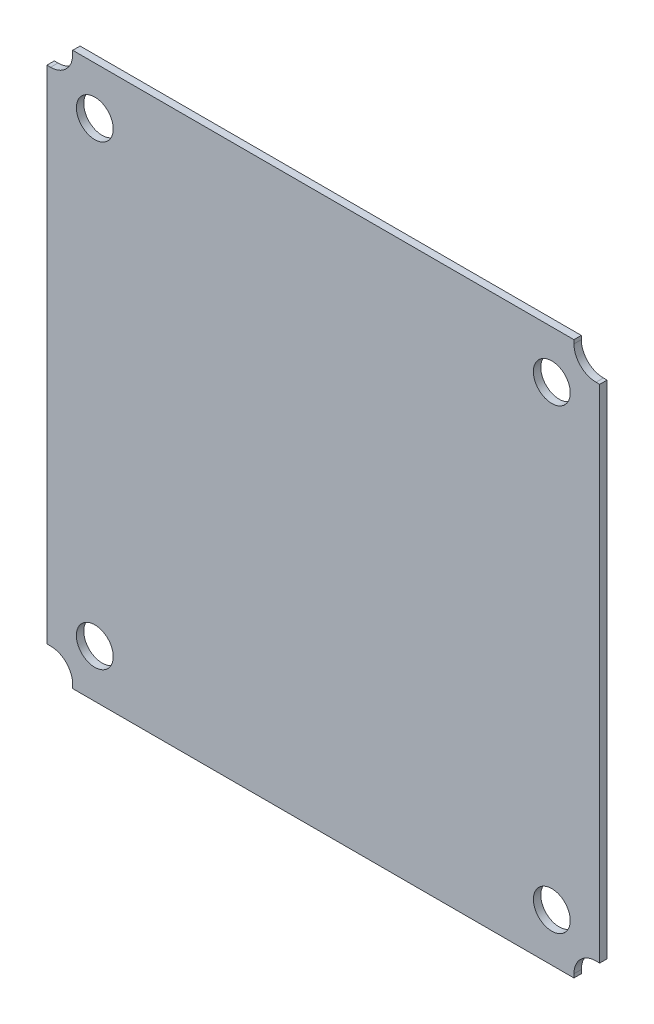
from build123d import *

# Parameters (mm, degrees)
SKETCH_1_W          = 68
SKETCH_1_H          = 68
SKETCH_1_R          = 2.5
SKETCH_1_H_2        = 11
SKETCH_1_W_2        = 11
EXTRUDE_2_DEPTH     = 1
FILLET_1_R          = 3
SKETCH_2_W          = 7.5
SKETCH_2_H          = 68
SKETCH_2_W_2        = 68
SKETCH_2_H_2        = 7.5
CUT_EXTRUDE_1_DEPTH = 2


with BuildPart() as part:
    # ｽｹｯﾁ1 → ﾎﾞｽ - 押し出し2 (new body)
    with BuildSketch(Plane.XY):
        Rectangle(SKETCH_1_W, SKETCH_1_H)
        with Locations((-31, -31)):
            Circle(SKETCH_1_R, mode=Mode.SUBTRACT)
        with Locations((31, -31)):
            Circle(SKETCH_1_R, mode=Mode.SUBTRACT)
        with Locations((-31, 31)):
            Circle(SKETCH_1_R, mode=Mode.SUBTRACT)
        with Locations((31, 31)):
            Circle(SKETCH_1_R, mode=Mode.SUBTRACT)
        with Locations((0, 39.5)):
            Rectangle(SKETCH_1_W, SKETCH_1_H_2)
        with Locations((-39.5, 0)):
            Rectangle(SKETCH_1_W_2, SKETCH_1_H)
        with Locations((39.5, 0)):
            Rectangle(SKETCH_1_W_2, SKETCH_1_H)
        with Locations((0, -39.5)):
            Rectangle(SKETCH_1_W, SKETCH_1_H_2)
    extrude(amount=EXTRUDE_2_DEPTH)

    # ﾌｨﾚｯﾄ1
    fillet_1_edges = [part.edges().sort_by_distance(p)[0] for p in [
        (-34, -34, 0.5),
        (-34, 34, 0.5),
        (34, 34, 0.5),
        (34, -34, 0.5),
    ]]
    fillet(fillet_1_edges, radius=FILLET_1_R)

    # ｽｹｯﾁ2 → ｶｯﾄ - 押し出し1 (cut, through all)
    with BuildSketch(Plane.XY.offset(1)):
        with Locations((-41.25, 0)):
            Rectangle(SKETCH_2_W, SKETCH_2_H)
        with Locations((0, 41.25)):
            Rectangle(SKETCH_2_W_2, SKETCH_2_H_2)
        with Locations((41.25, 0)):
            Rectangle(SKETCH_2_W, SKETCH_2_H)
        with Locations((0, -41.25)):
            Rectangle(SKETCH_2_W_2, SKETCH_2_H_2)
    extrude(amount=-CUT_EXTRUDE_1_DEPTH, mode=Mode.SUBTRACT)


solid = part.part
